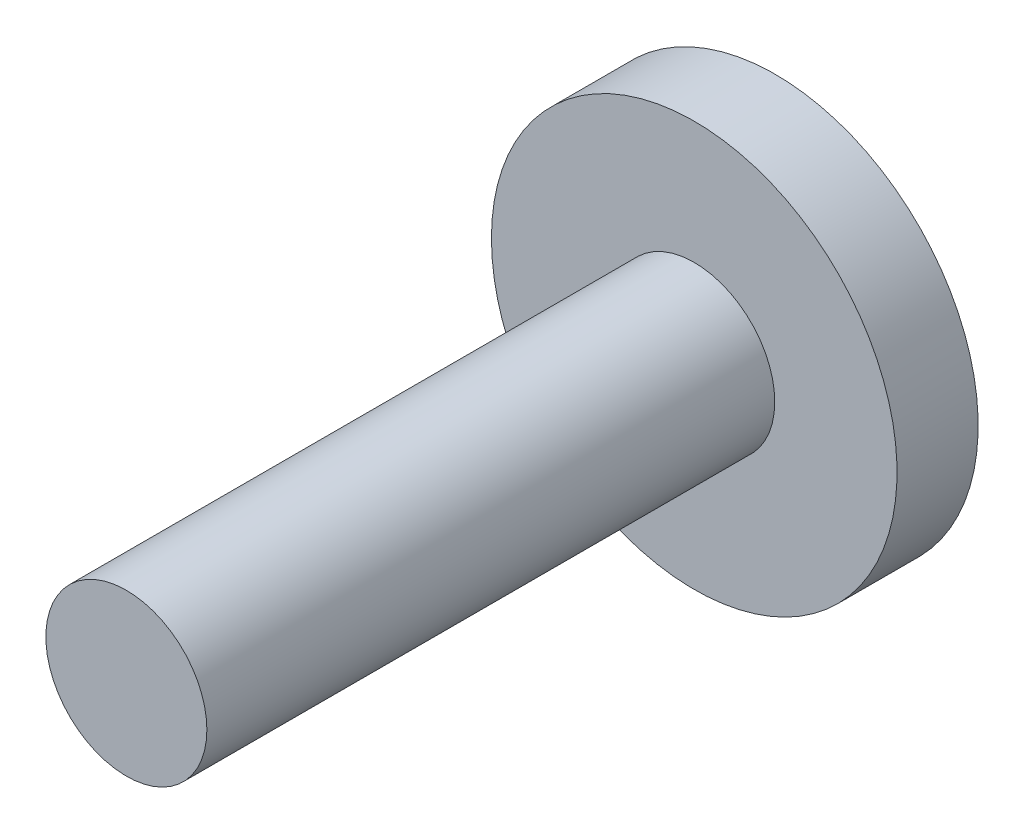
from build123d import *

# Parameters (mm, degrees)
CROQUIS1_R              = 1.985
SALIENTE_EXTRUIR1_DEPTH = 14
CROQUIS2_R              = 5
SALIENTE_EXTRUIR2_DEPTH = 2


with BuildPart() as part:
    # Croquis1 → Saliente-Extruir1 (new body)
    with BuildSketch(Plane.XY):
        Circle(CROQUIS1_R)
    extrude(amount=SALIENTE_EXTRUIR1_DEPTH)

    # Croquis2 → Saliente-Extruir2 (add)
    with BuildSketch(Plane(origin=(0, 0, 0), x_dir=(-1, 0, 0), z_dir=(0, 0, -1))):
        Circle(CROQUIS2_R)
    extrude(amount=SALIENTE_EXTRUIR2_DEPTH)


solid = part.part
